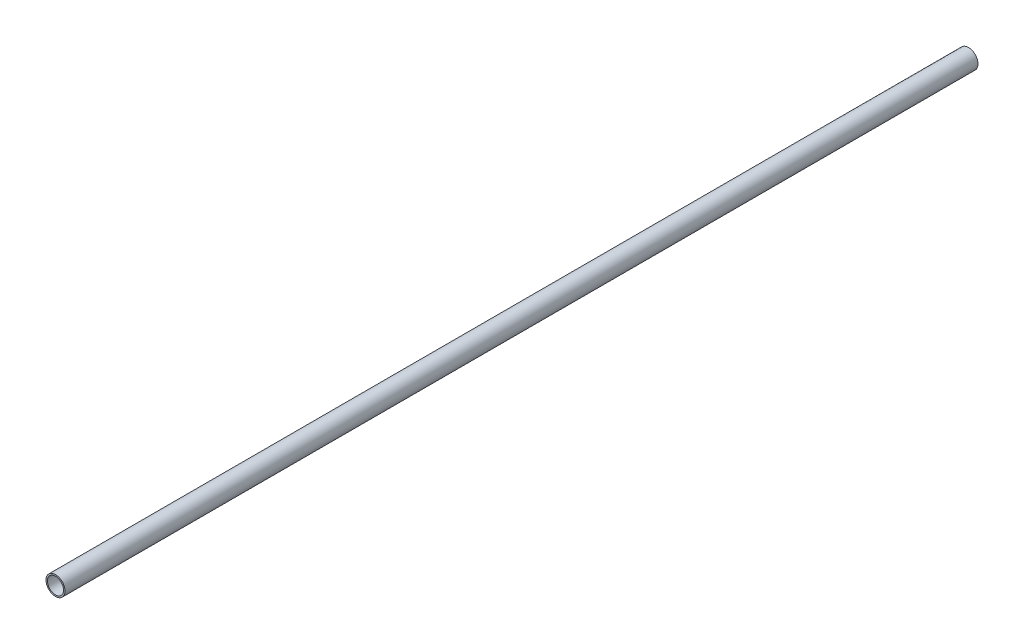
from build123d import *

# Parameters (mm, degrees)
PIPESKETCH_R    = 57.15
PIPESKETCH_R_2  = 48.5902
EXTRUSION_DEPTH = 5486.4


with BuildPart() as part:
    # PipeSketch → Extrusion (new body)
    with BuildSketch(Plane.XY):
        Circle(PIPESKETCH_R)
        Circle(PIPESKETCH_R_2, mode=Mode.SUBTRACT)
    extrude(amount=EXTRUSION_DEPTH)


solid = part.part
